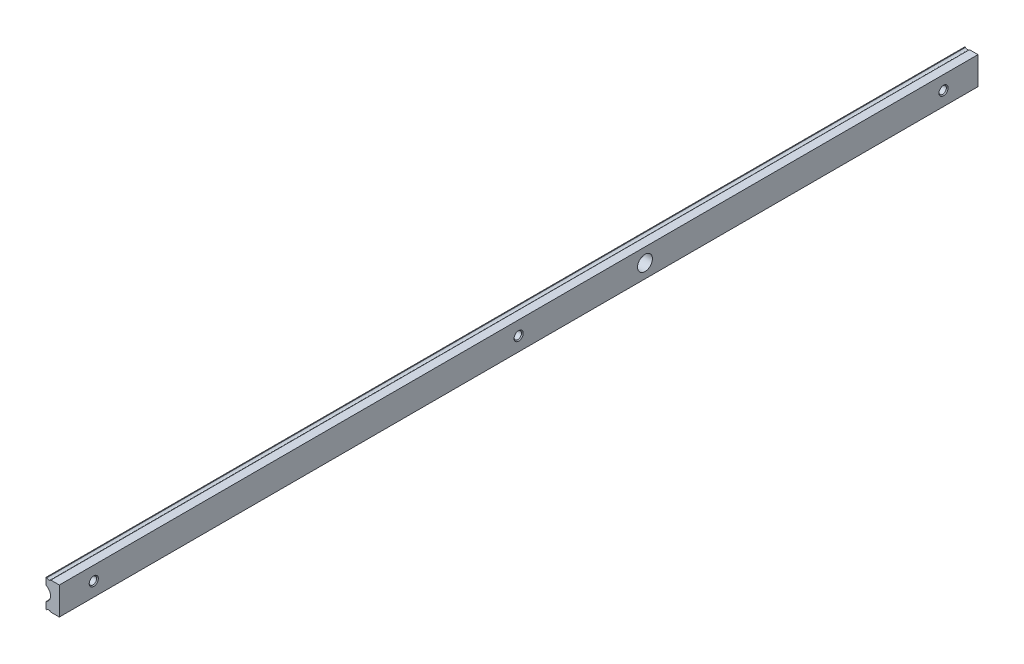
from build123d import *

# Parameters (mm, degrees)
BOSS_EXTRUDE1_DEPTH = 400
SKETCH5_R           = 3.25
CUT_EXTRUDE1_DEPTH  = 6


with BuildPart() as part:
    # Sketch1 → Boss-Extrude1 (new body)
    with BuildSketch(Plane.XY):
        with BuildLine():
            Line((0, 2.974695), (0, 0))
            Line((0, 0), (0.305573, 0))
            ThreePointArc((0.305573, 0), (1.2, 0.4), (2.094427, 0))
            Line((2.094427, 0), (5.8, 0))
            Line((5.8, 0), (5.8, 12.1))
            Line((5.8, 12.1), (2.094427, 12.1))
            ThreePointArc((2.094427, 12.1), (1.2, 11.7), (0.305573, 12.1))
            Line((0.305573, 12.1), (0, 12.1))
            Line((0, 12.1), (0, 9.125305))
            ThreePointArc((0, 9.125305), (1.95, 6.05), (0, 2.974695))
        make_face()
    extrude(amount=BOSS_EXTRUDE1_DEPTH)

    # Sketch2 → Cut-Revolve1 (revolve, cut)
    with BuildSketch(Plane.XY.offset(15)):
        Polygon((1.299545, 6.05), (1.299545, 8.05), (1.678545, 7.671), (5.421, 7.671), (5.8, 8.05), (5.8, 6.05), align=None)
    revolve(axis=Axis((5.8, 6.05, 15), (-1, 0, 0)), mode=Mode.SUBTRACT)

    # Sketch3 → Cut-Revolve2 (revolve, cut)
    with BuildSketch(Plane.XY.offset(385)):
        Polygon((1.299545, 6.05), (1.299545, 8.05), (1.678545, 7.671), (5.421, 7.671), (5.8, 8.05), (5.8, 6.05), align=None)
    revolve(axis=Axis((5.8, 6.05, 385), (-1, 0, 0)), mode=Mode.SUBTRACT)

    # Sketch4 → Cut-Revolve3 (revolve, cut)
    with BuildSketch(Plane.XY.offset(200)):
        Polygon((1.299545, 6.05), (1.299545, 8.05), (1.678545, 7.671), (5.421, 7.671), (5.8, 8.05), (5.8, 6.05), align=None)
    revolve(axis=Axis((5.8, 6.05, 200), (-1, 0, 0)), mode=Mode.SUBTRACT)

    # Sketch5 → Cut-Extrude1 (cut)
    with BuildSketch(Plane(origin=(5.8, 0, 0), x_dir=(0, 0, -1), z_dir=(1, 0, 0))):
        with Locations((-145, 6.05)):
            Circle(SKETCH5_R)
    extrude(amount=-CUT_EXTRUDE1_DEPTH, mode=Mode.SUBTRACT)


solid = part.part
